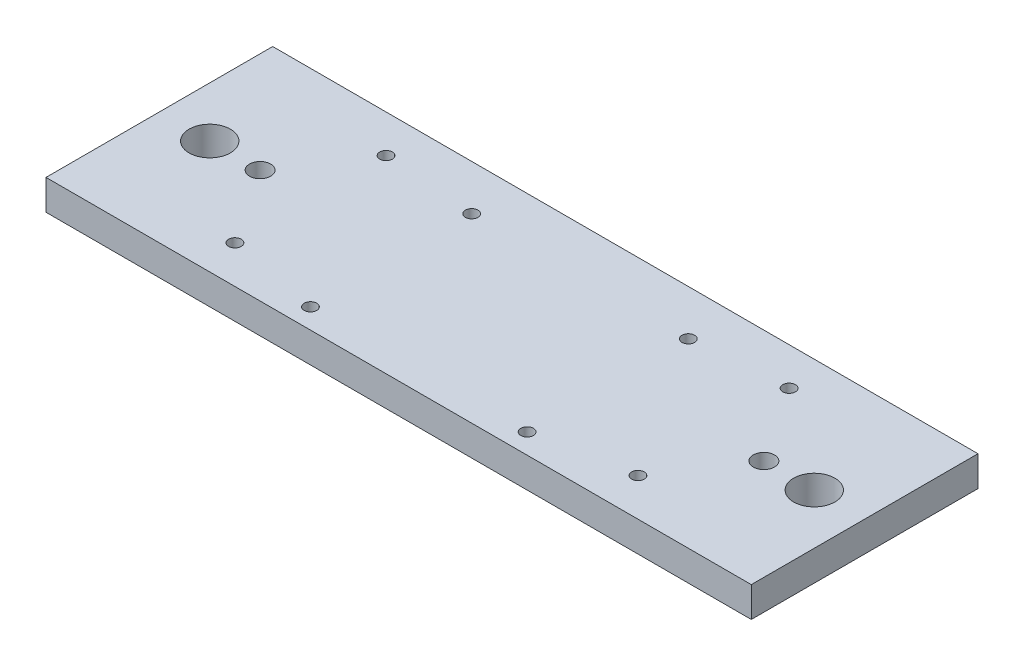
from build123d import *

# Parameters (mm, degrees)
SKETCH_1_W              = 140
SKETCH_1_H              = 45
SKETCH_1_R              = 4.1
SKETCH_1_R_2            = 0.5
EXTRUDE_1_DEPTH         = 6
M3_TAPPED_HOLE5_D       = 2.5
M3_TAPPED_HOLE2_D       = 2.5
HOLE_WIZARD_4_2_4_2_1_D = 4.2


with BuildPart() as part:
    # 草图1 → 凸台-拉伸1 (new body)
    with BuildSketch(Plane(origin=(0, 0, 0), x_dir=(1, 0, 0), z_dir=(0, 1, 0))):
        Rectangle(SKETCH_1_W, SKETCH_1_H)
        with Locations((60, 0)):
            Circle(SKETCH_1_R, mode=Mode.SUBTRACT)
        with Locations((-60, 0)):
            Circle(SKETCH_1_R, mode=Mode.SUBTRACT)
        with Locations((-40, 15)):
            Circle(SKETCH_1_R_2, mode=Mode.SUBTRACT)
        with Locations((40, 15)):
            Circle(SKETCH_1_R_2, mode=Mode.SUBTRACT)
        with Locations((40, -15)):
            Circle(SKETCH_1_R_2, mode=Mode.SUBTRACT)
        with Locations((-40, -15)):
            Circle(SKETCH_1_R_2, mode=Mode.SUBTRACT)
    extrude(amount=EXTRUDE_1_DEPTH)

    # M3 Tapped Hole5 (through all)
    with Locations(Plane(origin=(0, 6, 0), x_dir=(1, 0, 0), z_dir=(0, 1, 0))):
        with Locations((-40, 15), (-40, -15), (40, -15), (40, 15)):
            Hole(M3_TAPPED_HOLE5_D / 2)

    # M3 Tapped Hole2 (through all)
    with Locations(Plane(origin=(0, 6, 0), x_dir=(1, 0, 0), z_dir=(0, 1, 0))):
        with Locations((-21.5, 13.5), (21.5, 13.5), (21.5, -18.5), (-21.5, -18.5)):
            Hole(M3_TAPPED_HOLE2_D / 2)

    # Ø4.2 (4.2) 直径孔1 (through all)
    with Locations(Plane(origin=(0, 6, 0), x_dir=(1, 0, 0), z_dir=(0, 1, 0))):
        with Locations((50, 0), (-50, 0)):
            Hole(HOLE_WIZARD_4_2_4_2_1_D / 2)


solid = part.part
